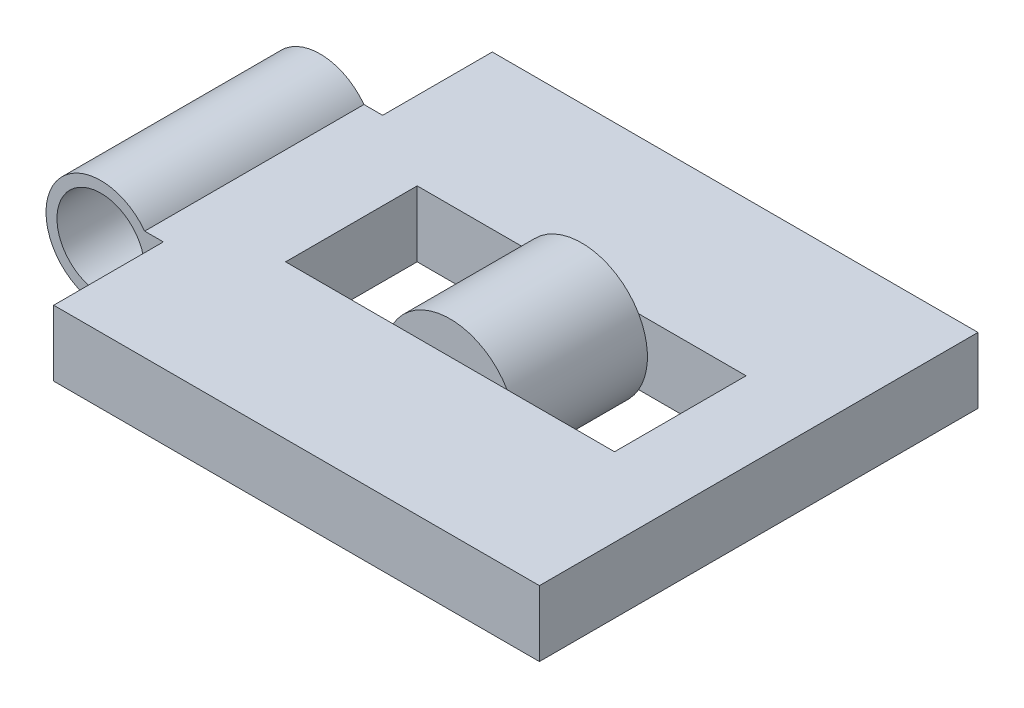
from build123d import *

# Parameters (mm, degrees)
SKETCH1_R               = 12.7
SKETCH1_R_2             = 10.16
SKETCH1_W               = 116.84
SKETCH1_H               = 15.24
BOSS_EXTRUDE1_DEPTH     = 101.6
SKETCH2_W               = 27.184704077
SKETCH2_H               = 25.4
CUT_EXTRUDE1_DEPTH      = 6.08
CUT_EXTRUDE1_DEPTH_BACK = 21.32
SKETCH3_W               = 76.2
SKETCH3_H               = 30.48
CUT_EXTRUDE2_DEPTH      = 21.32
SKETCH4_R               = 15.24
BOSS_EXTRUDE2_DEPTH     = 30.48


with BuildPart() as part:
    # Sketch1 → Boss-Extrude1 (new body)
    with BuildSketch(Plane.XY):
        Circle(SKETCH1_R)
        Circle(SKETCH1_R_2, mode=Mode.SUBTRACT)
        with Locations((68.58, 0)):
            Rectangle(SKETCH1_W, SKETCH1_H)
    extrude(amount=BOSS_EXTRUDE1_DEPTH)

    # Sketch2 → Cut-Extrude1 (cut, two sides)
    with BuildSketch(Plane(origin=(0, 7.62, 0), x_dir=(1, 0, 0), z_dir=(0, 1, 0))) as cut_extrude1_sk:
        with Locations((0.892352039, -88.9)):
            Rectangle(SKETCH2_W, SKETCH2_H)
        with Locations((0.892352039, -12.7)):
            Rectangle(SKETCH2_W, SKETCH2_H)
    extrude(amount=CUT_EXTRUDE1_DEPTH, mode=Mode.SUBTRACT)
    extrude(cut_extrude1_sk.sketch, amount=-CUT_EXTRUDE1_DEPTH_BACK, mode=Mode.SUBTRACT)

    # Sketch3 → Cut-Extrude2 (cut, through all)
    with BuildSketch(Plane.XZ.offset(7.62)):
        with Locations((70.742352039, 50.8)):
            Rectangle(SKETCH3_W, SKETCH3_H)
    extrude(amount=-CUT_EXTRUDE2_DEPTH, mode=Mode.SUBTRACT)

    # Sketch4 → Boss-Extrude2 (add)
    with BuildSketch(Plane.XY.offset(35.56)):
        with Locations((70.742352039, 0)):
            Circle(SKETCH4_R)
    extrude(amount=BOSS_EXTRUDE2_DEPTH)


solid = part.part
